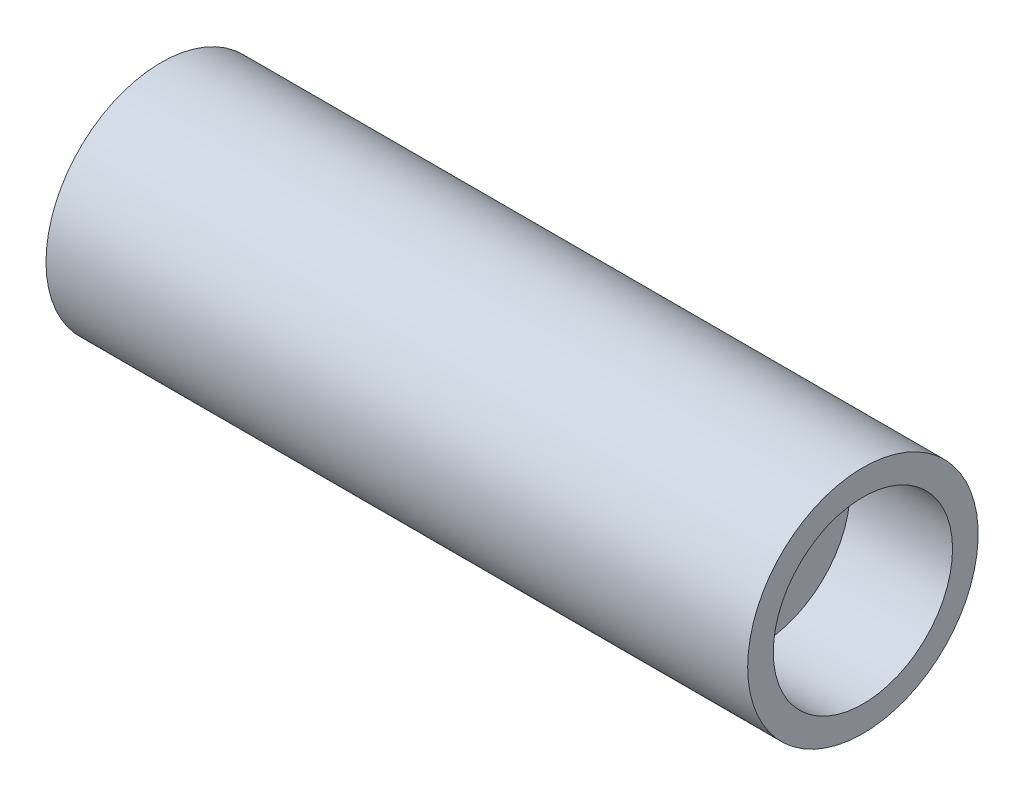
from build123d import *


with BuildPart() as part:
    # Sketch1 → Revolve1 (revolve)
    with BuildSketch(Plane.XY):
        Polygon((9.7, 3.5), (13.7, 3.5), (13.7, 4.5), (-13.7, 4.5), (-13.7, 3.5), (-9.7, 3.5), (-9.7, 2), (9.7, 2), align=None)
    revolve(axis=Axis((-6.495464487, 0, 0), (1, 0, 0)))


solid = part.part
